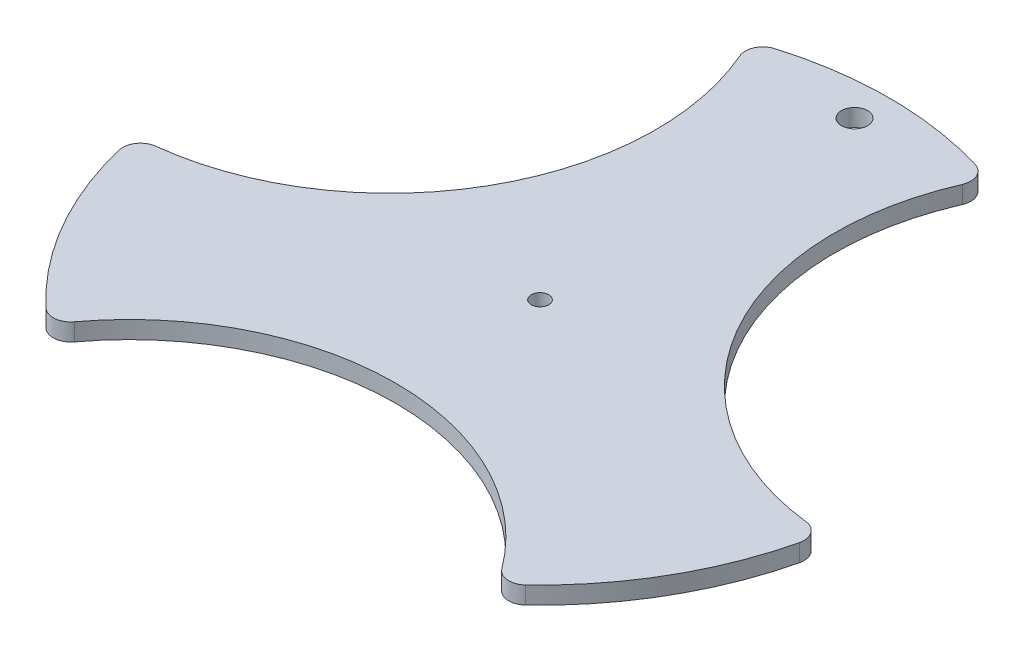
from build123d import *

# Parameters (mm, degrees)
SKETCH1_R           = 40
BOSS_EXTRUDE1_DEPTH = 2
SKETCH5_R           = 1.5
CUT_EXTRUDE2_DEPTH  = 3
SKETCH7_R           = 1
CUT_EXTRUDE4_DEPTH  = 3
SKETCH8_R           = 30.471270003
CUT_EXTRUDE5_DEPTH  = 3
CIRPATTERN1_COUNT   = 3
FILLET1_R           = 2


with BuildPart() as part:
    # Sketch1 → Boss-Extrude1 (new body)
    with BuildSketch(Plane(origin=(0, 0, 0), x_dir=(1, 0, 0), z_dir=(0, 1, 0))):
        Circle(SKETCH1_R)
    extrude(amount=BOSS_EXTRUDE1_DEPTH)

    # Sketch5 → Cut-Extrude2 (cut, through all)
    with BuildSketch(Plane(origin=(0, 2, 0), x_dir=(1, 0, 0), z_dir=(0, 1, 0))):
        with Locations((0, 36)):
            Circle(SKETCH5_R)
    extrude(amount=-CUT_EXTRUDE2_DEPTH, mode=Mode.SUBTRACT)

    # Sketch7 → Cut-Extrude4 (cut, through all)
    with BuildSketch(Plane(origin=(0, 2, 0), x_dir=(1, 0, 0), z_dir=(0, 1, 0))):
        Circle(SKETCH7_R)
    extrude(amount=-CUT_EXTRUDE4_DEPTH, mode=Mode.SUBTRACT)

    # Sketch8 → Cut-Extrude5 (cut, through all)
    with BuildSketch(Plane(origin=(0, 2, 0), x_dir=(1, 0, 0), z_dir=(0, 1, 0))):
        with Locations((40.698571494, 23.497331208)):
            Circle(SKETCH8_R)
    cut_extrude5 = extrude(amount=-CUT_EXTRUDE5_DEPTH, mode=Mode.SUBTRACT)

    # CirPattern1: Cut-Extrude5 ×3 about axis
    cirpattern1_axis = Axis((0, 0, 0), (0, 1, 0))
    for i in range(1, CIRPATTERN1_COUNT):
        add(cut_extrude5.rotate(cirpattern1_axis, i * 360 / CIRPATTERN1_COUNT), mode=Mode.SUBTRACT)

    # Fillet1
    fillet1_edges = [part.edges().sort_by_distance(p)[0] for p in [
        (39.39231012, 1, 6.945927107),
        (13.680805733, 1, -37.587704831),
        (-25.711504387, 1, 30.641777725),
        (25.711504387, 1, 30.641777725),
        (-13.680805733, 1, -37.587704831),
        (-39.39231012, 1, 6.945927107),
    ]]
    fillet(fillet1_edges, radius=FILLET1_R)


solid = part.part
